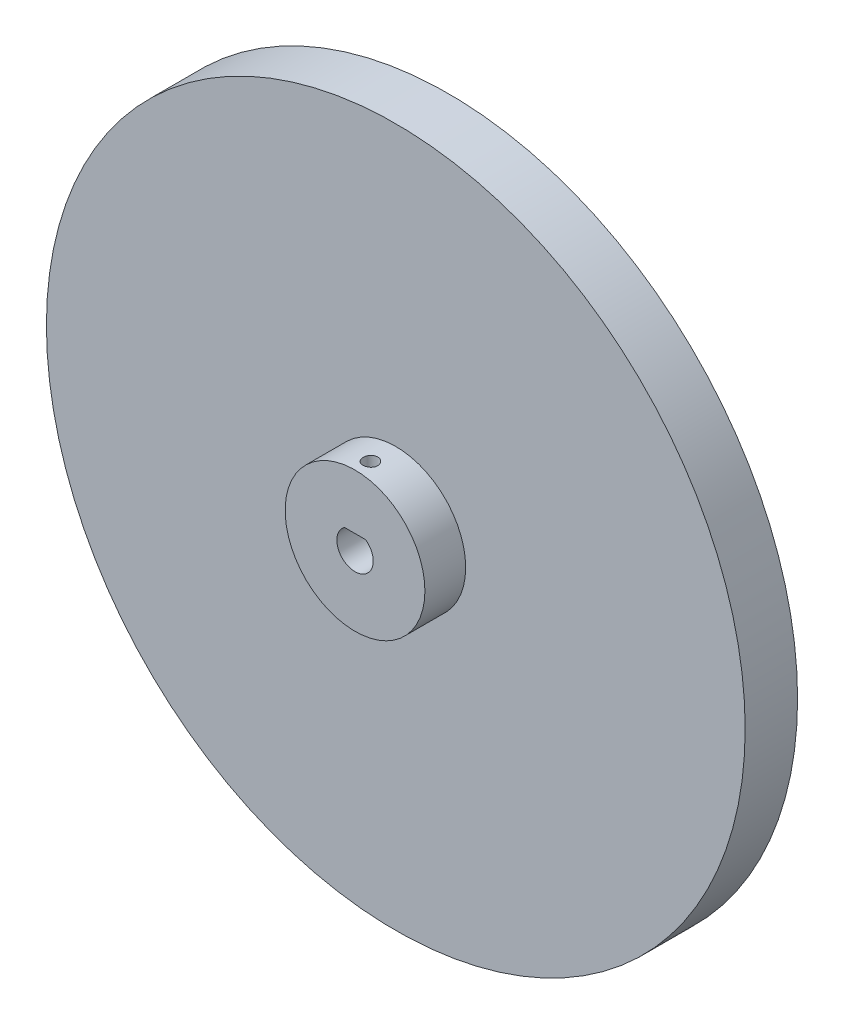
from build123d import *

# Parameters (mm, degrees)
ESBO_O1_R                = 60
RESSALTO_EXTRUS_O1_DEPTH = 9
ESBO_O3_R                = 12
RESSALTO_EXTRUS_O2_DEPTH = 7
ESBO_O4_R                = 1.25
CORTE_EXTRUS_O1_DEPTH    = 10


with BuildPart() as part:
    # Esboço1 → Ressalto-extrusão1 (new body)
    with BuildSketch(Plane.XY):
        Circle(ESBO_O1_R)
        with BuildLine():
            Line((-1.80641219, 2.55), (1.80641219, 2.55))
            ThreePointArc((1.80641219, 2.55), (0, -3.125), (-1.80641219, 2.55))
        make_face(mode=Mode.SUBTRACT)
    extrude(amount=RESSALTO_EXTRUS_O1_DEPTH)

    # Esboço3 → Ressalto-extrusão2 (add)
    with BuildSketch(Plane.XY.offset(9)):
        Circle(ESBO_O3_R)
        with BuildLine():
            Line((-1.80641219, 2.55), (1.80641219, 2.55))
            ThreePointArc((1.80641219, 2.55), (0, -3.125), (-1.80641219, 2.55))
        make_face(mode=Mode.SUBTRACT)
    extrude(amount=RESSALTO_EXTRUS_O2_DEPTH)

    # Esboço4 → Corte-extrusão1 (cut)
    with BuildSketch(Plane.XZ.offset(-2.55)):
        with Locations((0, 13.363805145)):
            Circle(ESBO_O4_R)
    extrude(amount=-CORTE_EXTRUS_O1_DEPTH, mode=Mode.SUBTRACT)


solid = part.part
